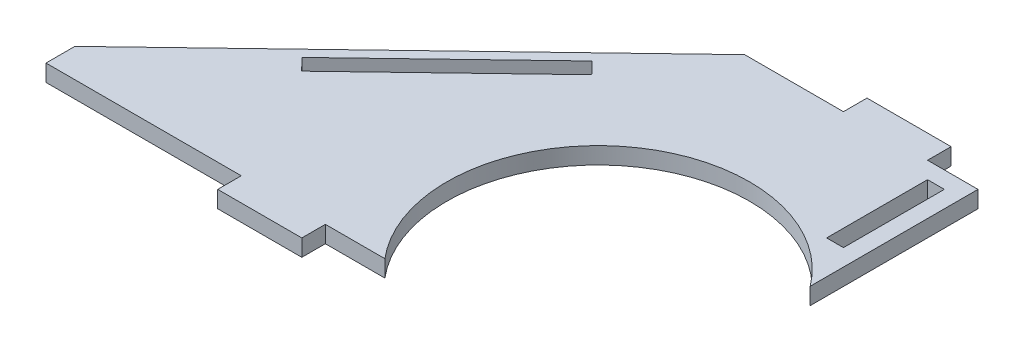
from build123d import *

# Parameters (mm, degrees)
BOSS_EXTRUDE1_DEPTH = 5
CUT_EXTRUDE1_DEPTH  = 6
CUT_EXTRUDE2_DEPTH  = 6
SKETCH6_W           = 5
SKETCH6_H           = 30
CUT_EXTRUDE4_DEPTH  = 6
CUT_EXTRUDE5_DEPTH  = 6


with BuildPart() as part:
    # Sketch1 → Boss-Extrude1 (new body)
    with BuildSketch(Plane(origin=(0, 0, 0), x_dir=(1, 0, 0), z_dir=(0, 1, 0))):
        with BuildLine():
            Line((-90, -43), (-90, 63))
            Line((-90, 63), (50, 63))
            Line((50, 63), (50, 70))
            Line((50, 70), (75, 70))
            Line((75, 70), (75, 63))
            Line((75, 63), (90, 63))
            Line((90, 63), (90, 13.132821453))
            ThreePointArc((90, 13.132821453), (26.02369403, 21.167044845), (19.690698932, -43))
            Line((19.690698932, -43), (2, -43))
            Line((2, -43), (2, -50))
            Line((2, -50), (-23, -50))
            Line((-23, -50), (-23, -43))
            Line((-23, -43), (-90, -43))
        make_face()
    extrude(amount=BOSS_EXTRUDE1_DEPTH)

    # Sketch2 → Cut-Extrude1 (cut, through all)
    with BuildSketch(Plane(origin=(0, 5, 0), x_dir=(1, 0, 0), z_dir=(0, 1, 0))):
        Polygon((-90, -43), (20.646102312, 63), (-90, 63), align=None)
    extrude(amount=-CUT_EXTRUDE1_DEPTH, mode=Mode.SUBTRACT)

    # Sketch4 → Cut-Extrude2 (cut, through all)
    with BuildSketch(Plane(origin=(0, 5, 0), x_dir=(1, 0, 0), z_dir=(0, 1, 0))):
        Polygon((-1.099353578, 38.01312996), (-44.425657525, -3.493874103), (-40.966740519, -7.104399432), (2.359563427, 34.402604632), (3.081668493, 35.094388033), (-0.377248513, 38.704913361), align=None)
    extrude(amount=-CUT_EXTRUDE2_DEPTH, mode=Mode.SUBTRACT)

    # Sketch6 → Cut-Extrude4 (cut, through all)
    with BuildSketch(Plane(origin=(0, 5, 0), x_dir=(1, 0, 0), z_dir=(0, 1, 0))):
        with Locations((82.5, 43)):
            Rectangle(SKETCH6_W, SKETCH6_H)
    extrude(amount=-CUT_EXTRUDE4_DEPTH, mode=Mode.SUBTRACT)

    # Sketch8 → Cut-Extrude5 (cut, through all)
    with BuildSketch(Plane(origin=(0, 5, 0), x_dir=(1, 0, 0), z_dir=(0, 1, 0))):
        Polygon((-81.041343938, -43), (-81.041343938, -34.417523775), (-90, -43), align=None)
    extrude(amount=-CUT_EXTRUDE5_DEPTH, mode=Mode.SUBTRACT)


solid = part.part
